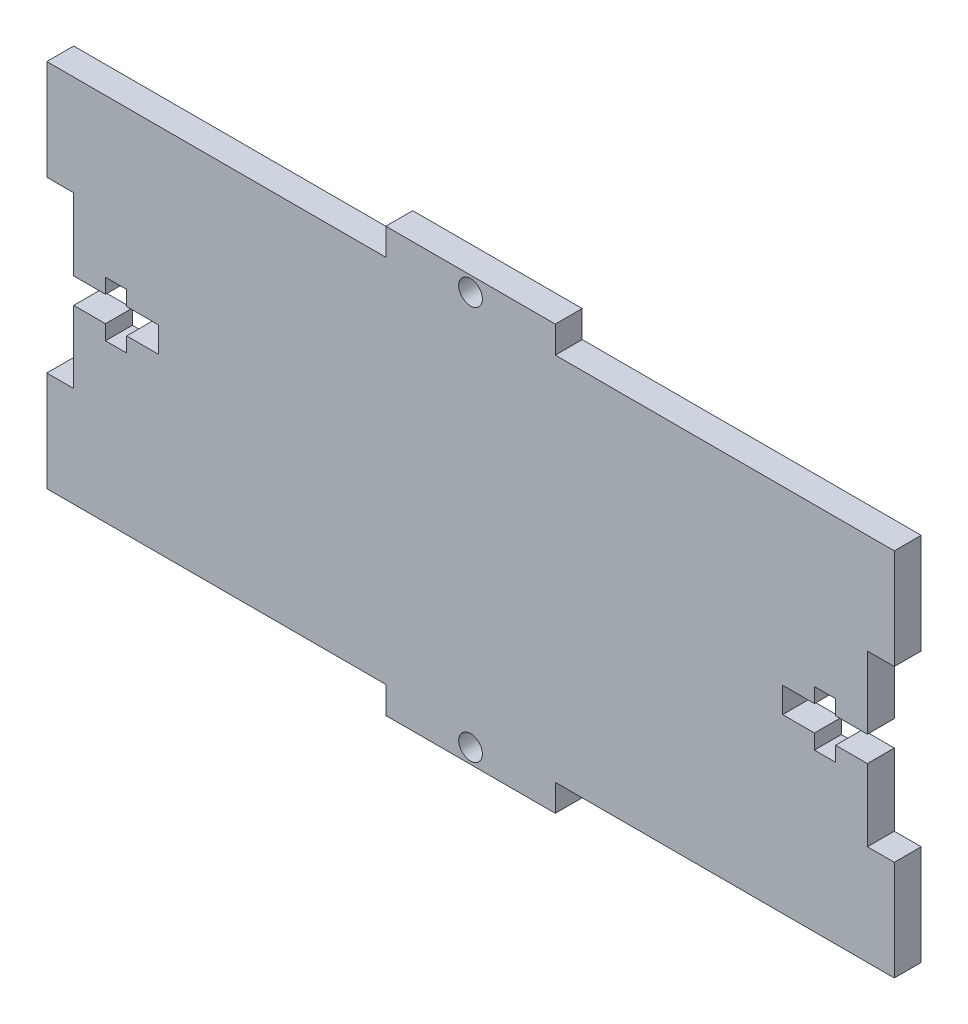
from build123d import *

# Parameters (mm, degrees)
SKETCH1_W           = 100
SKETCH1_H           = 50
BOSS_EXTRUDE1_DEPTH = 3.175
SKETCH5_R           = 1.4
SKETCH5_W           = 40
SKETCH5_H           = 3.175
CUT_EXTRUDE1_DEPTH  = 4.175
T_CUT_DEPTH         = 4.175
T_CUT2_DEPTH        = 4.175


with BuildPart() as part:
    # Sketch1 → Boss-Extrude1 (new body)
    with BuildSketch(Plane.XY):
        Rectangle(SKETCH1_W, SKETCH1_H)
    extrude(amount=BOSS_EXTRUDE1_DEPTH)

    # Sketch5 → Cut-Extrude1 (cut, through all)
    with BuildSketch(Plane(origin=(-7.388521522, -2.556187212, 3.175), x_dir=(1, 0, 0), z_dir=(0, 0, 1))):
        with Locations((7.388521522, 25.806187212)):
            Circle(SKETCH5_R)
        with Locations((-22.611478478, 25.968687212)):
            Rectangle(SKETCH5_W, SKETCH5_H)
        with Locations((37.388521522, 25.968687212)):
            Rectangle(SKETCH5_W, SKETCH5_H)
    cut_extrude1 = extrude(amount=-CUT_EXTRUDE1_DEPTH, mode=Mode.SUBTRACT)

    # Mirror1: Cut-Extrude1 across plane
    add(cut_extrude1.mirror(Plane.ZX), mode=Mode.SUBTRACT)

    # Sketch3 → T Cut (cut, through all)
    with BuildSketch(Plane(origin=(2.435372351, -11.560763397, 0), x_dir=(-1, 0, 0), z_dir=(0, 0, -1))):
        Polygon((-47.564627649, 1.560763397), (-47.564627649, 21.560763397), (-44.389627649, 21.560763397), (-44.389627649, 13.060763397), (-40.639627649, 13.060763397), (-40.639627649, 14.810763397), (-38.139627649, 14.810763397), (-38.139627649, 13.060763397), (-34.389627649, 13.060763397), (-34.389627649, 10.060763397), (-38.139627649, 10.060763397), (-38.139627649, 8.310763397), (-40.639627649, 8.310763397), (-40.639627649, 10.060763397), (-44.389627649, 10.060763397), (-44.389627649, 1.560763397), align=None)
    extrude(amount=-T_CUT_DEPTH, mode=Mode.SUBTRACT)

    # Sketch32 → T Cut2 (cut, through all)
    with BuildSketch(Plane(origin=(-11.542281755, -7.322180687, 3.175), x_dir=(1, 0, 0), z_dir=(0, 0, 1))):
        Polygon((-38.457718245, -2.677819313), (-38.457718245, 17.322180687), (-35.282718245, 17.322180687), (-35.282718245, 8.822180687), (-31.532718245, 8.822180687), (-31.532718245, 10.572180687), (-29.032718245, 10.572180687), (-29.032718245, 8.822180687), (-25.282718245, 8.822180687), (-25.282718245, 5.822180687), (-29.032718245, 5.822180687), (-29.032718245, 4.072180687), (-31.532718245, 4.072180687), (-31.532718245, 5.822180687), (-35.282718245, 5.822180687), (-35.282718245, -2.677819313), align=None)
    extrude(amount=-T_CUT2_DEPTH, mode=Mode.SUBTRACT)


solid = part.part
